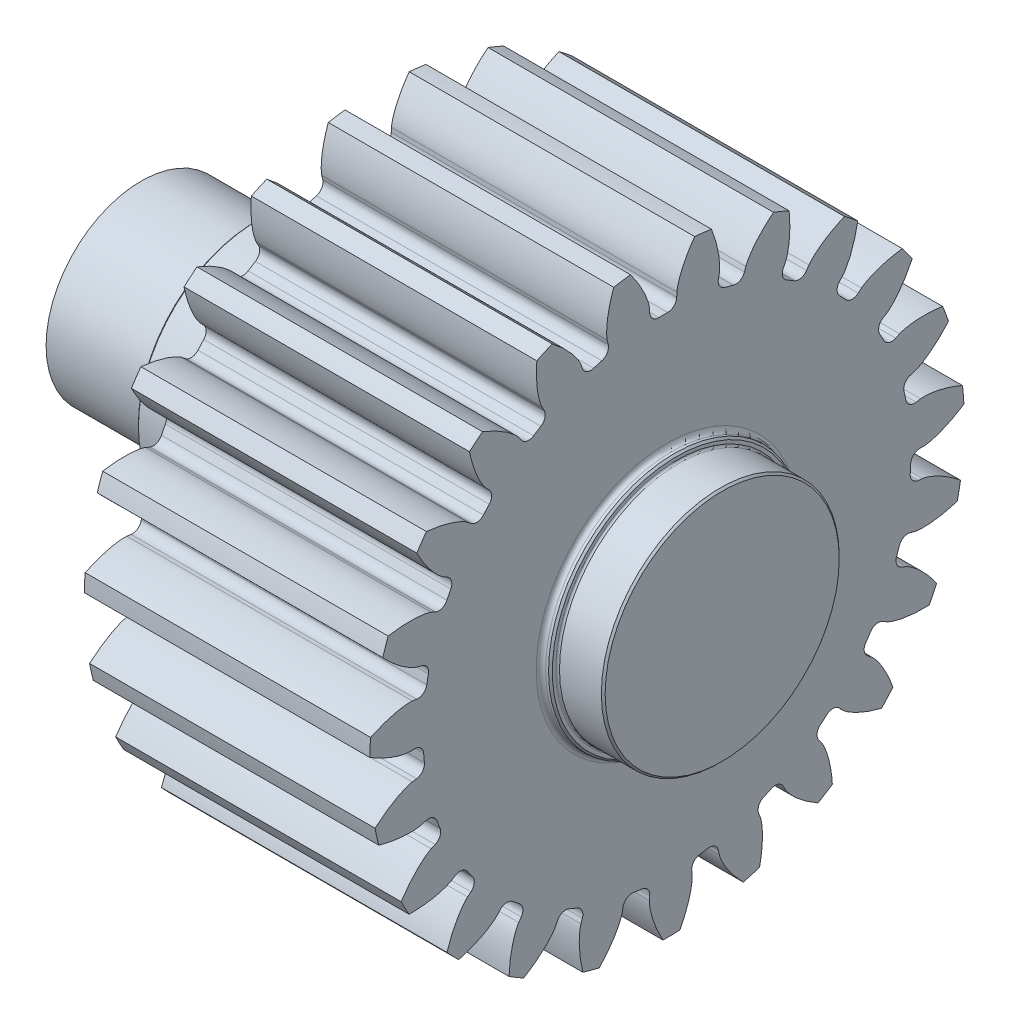
from build123d import *

# Parameters (mm, degrees)
SKETCH5_R                = 31.25
BOSS_EXTRUDE1_DEPTH      = 30
CUT_EXTRUDE2_DEPTH       = 30
FILLET2_R                = 0.95
CIRPATTERN3_COUNT        = 23
FILLET2_OF_CIRPATTERN3_R = 0.95
SKETCH12_R               = 13.25
BOSS_EXTRUDE4_DEPTH      = 1
SKETCH10_R               = 12.5
BOSS_EXTRUDE2_DEPTH      = 43.25
BOSS_EXTRUDE3_START      = -13.25
SKETCH11_R               = 10
BOSS_EXTRUDE3_DEPTH      = 12
BEARINGHOUSEFILLET_R     = 0.2
CHAMFER1_SIZE            = 0.2
FILLET4_R                = 0.5
BOSS_EXTRUDE5_START      = -43.25
SKETCH14_R               = 12.5
BOSS_EXTRUDE5_DEPTH      = 5.8
BOSS_EXTRUDE6_START      = -43.25
SKETCH14_3_R             = 13.25
SKETCH14_3_R_2           = 12.5
BOSS_EXTRUDE6_DEPTH      = 1
CHAMFER2_SIZE            = 0.2
FILLET5_R                = 0.2
FILLET6_R                = 0.5


with BuildPart() as part:
    # Sketch5 → Boss-Extrude1 (new body)
    with BuildSketch(Plane(origin=(0, 0, 0), x_dir=(0, 0, -1), z_dir=(1, 0, 0))):
        Circle(SKETCH5_R)
    extrude(amount=BOSS_EXTRUDE1_DEPTH)

    # Sketch8 → Cut-Extrude2 (cut)
    with BuildSketch(Plane(origin=(30, 0, 0), x_dir=(0, 0, -1), z_dir=(1, 0, 0))):
        with BuildLine():
            Line((27.016162848, 0), (25.625, 0))
            ThreePointArc((25.625, 0), (25.588485255, -1.367496741), (25.479045086, -2.73109621))
            Line((25.479045086, -2.73109621), (26.862284146, -2.879365462))
            add(Edge.make_bspline(
                [(26.862284146, -2.879365462), (26.874512586, -2.880882139), (26.908728932, -2.885764851), (26.973075717, -2.897476424), (27.077470202, -2.920091369), (27.20950929, -2.954038311), (27.378881389, -3.003771411), (27.576588009, -3.06984655), (27.791758211, -3.150250253), (28.023379435, -3.246062339), (28.252109809, -3.348966509), (28.477950784, -3.458370073), (28.700729243, -3.573407312), (28.967838406, -3.719835786), (29.284209391, -3.905222953), (29.647889042, -4.135986075), (30.052839087, -4.414164202), (30.405618835, -4.676716233), (30.650277923, -4.868872141), (30.795443065, -4.986981519), (30.843143694, -5.026229909)],
                knots=[0, 0, 0, 0, 0, 0.005376749, 0.015083688, 0.02853182, 0.046610139, 0.064854849, 0.092110525, 0.119476176, 0.146842496, 0.174208854, 0.201574956, 0.228941013, 0.256307345, 0.307035032, 0.361767352, 0.416499661, 0.471231936, 0.498147556, 0.498147556, 0.498147556, 0.498147556, 0.498147556], degree=4))
            ThreePointArc((30.843143694, -5.026229909), (31.205469824, -1.667678952), (31.203159657, 1.710358853))
            add(Edge.make_bspline(
                [(27.016162848, 0), (27.028483284, 0.000204739), (27.063025136, 0.001412884), (27.128253626, 0.006199711), (27.234463788, 0.017559547), (27.36936885, 0.037240492), (27.543076762, 0.068638752), (27.746699531, 0.113266094), (27.969213541, 0.17027913), (28.209727088, 0.240859447), (28.44812212, 0.318799557), (28.684336912, 0.403509993), (28.918107065, 0.494148416), (29.199301081, 0.611274537), (29.533628526, 0.761887157), (29.919831317, 0.952575153), (30.352122895, 1.186009514), (30.730875908, 1.40946706), (30.994621321, 1.574452876), (31.151547653, 1.676417917), (31.203159657, 1.710358853)],
                knots=[0, 0, 0, 0, 0, 0.005376749, 0.015083688, 0.02853182, 0.046610139, 0.064854849, 0.092110525, 0.119476176, 0.146842496, 0.174208854, 0.201574956, 0.228941013, 0.256307345, 0.307035032, 0.361767352, 0.416499661, 0.471231936, 0.498147556, 0.498147556, 0.498147556, 0.498147556, 0.498147556], degree=4))
        make_face()
    cut_extrude2 = extrude(amount=-CUT_EXTRUDE2_DEPTH, mode=Mode.SUBTRACT)

    # Fillet2
    fillet2_edges = [part.edges().sort_by_distance(p)[0] for p in [
        (15, -2.73109621, -25.479045086),
        (15, 0, -25.625),
    ]]
    fillet(fillet2_edges, radius=FILLET2_R)

    # CirPattern3: Cut-Extrude2 ×23 about axis
    cirpattern3_axis = Axis((30, 0, 0), (-1, 0, 0))
    for i in range(1, CIRPATTERN3_COUNT):
        add(cut_extrude2.rotate(cirpattern3_axis, i * 360 / CIRPATTERN3_COUNT), mode=Mode.SUBTRACT)

    # Fillet2 of CirPattern3
    fillet2_of_cirpattern3_edges = [part.edges().sort_by_distance(p)[0] for p in [
        (15, -9.50398385, -23.797372039),
        (15, -6.913542261, -24.674755488),
        (15, -15.572004486, -20.350756774),
        (15, -13.31433872, -21.894497242),
        (15, -20.485120787, -15.394818978),
        (15, -18.727671585, -17.490424295),
        (15, -23.878949392, -9.297117884),
        (15, -22.752058722, -11.789166592),
        (15, -25.501785559, -2.509892089),
        (15, -25.089029747, -5.213560334),
        (15, -25.233270955, 4.463480921),
        (15, -25.565262211, 1.748711842),
        (15, -23.093320078, 11.10581797),
        (15, -24.145436129, 8.581290062),
        (15, -19.240643296, 16.924487306),
        (15, -20.934853508, 14.777433254),
        (15, -13.960976021, 21.487944842),
        (15, -16.171628573, 19.877601824),
        (15, -7.645887021, 24.457739811),
        (15, -10.209027927, 23.503539601),
        (15, -0.763737559, 25.613616104),
        (15, -3.489270383, 25.386327367),
        (15, 6.175054824, 24.869847666),
        (15, 3.489270383, 25.386327367),
        (15, 12.65587164, 22.281596398),
        (15, 10.209027927, 23.503539601),
        (15, 18.198060353, 18.040821057),
        (15, 16.171628573, 19.877601824),
        (15, 22.39058218, 12.462040549),
        (15, 20.934853508, 14.777433254),
        (15, 24.922496957, 5.959007504),
        (15, 24.145436129, 8.581290062),
        (15, 25.606024148, -0.985977867),
        (15, 25.565262211, 1.748711842),
        (15, 24.390469667, -7.857837771),
        (15, 25.089029747, -5.213560334),
        (15, 21.36598563, -14.146917794),
        (15, 22.752058722, -11.789166592),
        (15, 16.756884182, -19.386785642),
        (15, 18.727671585, -17.490424295),
        (15, 10.905001291, -23.188824287),
        (15, 13.31433872, -21.894497242),
        (15, 4.244344342, -25.271053918),
        (15, 6.913542261, -24.674755488),
    ]]
    fillet(fillet2_of_cirpattern3_edges, radius=FILLET2_OF_CIRPATTERN3_R)

    # Sketch12 → Boss-Extrude4 (add)
    with BuildSketch(Plane(origin=(0, 0, 0), x_dir=(0, 0, -1), z_dir=(1, 0, 0))):
        Circle(SKETCH12_R)
    extrude(amount=-BOSS_EXTRUDE4_DEPTH)

    # Sketch10 → Boss-Extrude2 (add)
    with BuildSketch(Plane.ZY.offset(13.25)):
        Circle(SKETCH10_R)
    extrude(amount=-BOSS_EXTRUDE2_DEPTH)

    # Sketch11 → Boss-Extrude3 (add)
    with BuildSketch(Plane(origin=(0, 0, 0), x_dir=(0, 0, -1), z_dir=(1, 0, 0)).offset(BOSS_EXTRUDE3_START)):
        Circle(SKETCH11_R)
    extrude(amount=-BOSS_EXTRUDE3_DEPTH)

    # bearingHouseFillet
    bearinghousefillet_edges = [part.edges().sort_by_distance(p)[0] for p in [
        (-1, 0, -12.5),
    ]]
    fillet(bearinghousefillet_edges, radius=BEARINGHOUSEFILLET_R)

    # Chamfer1
    chamfer1_edges = [part.edges().sort_by_distance(p)[0] for p in [
        (-13.25, 0, -12.5),
    ]]
    chamfer(chamfer1_edges, length=CHAMFER1_SIZE)

    # Fillet4
    fillet4_edges = [part.edges().sort_by_distance(p)[0] for p in [
        (0, 0, 13.25),
    ]]
    fillet(fillet4_edges, radius=FILLET4_R)

    # Sketch14 → Boss-Extrude5 (add)
    with BuildSketch(Plane.ZY.offset(13.25).offset(BOSS_EXTRUDE5_START)):
        Circle(SKETCH14_R)
    extrude(amount=-BOSS_EXTRUDE5_DEPTH)

    # Sketch14_3 → Boss-Extrude6 (add)
    with BuildSketch(Plane.ZY.offset(13.25).offset(BOSS_EXTRUDE6_START)):
        Circle(SKETCH14_3_R)
        Circle(SKETCH14_3_R_2, mode=Mode.SUBTRACT)
    extrude(amount=-BOSS_EXTRUDE6_DEPTH)

    # Chamfer2
    chamfer2_edges = [part.edges().sort_by_distance(p)[0] for p in [
        (35.8, 0, -12.5),
        (31, 0, -13.25),
    ]]
    chamfer(chamfer2_edges, length=CHAMFER2_SIZE)

    # Fillet5
    fillet5_edges = [part.edges().sort_by_distance(p)[0] for p in [
        (31, 0, -12.5),
    ]]
    fillet(fillet5_edges, radius=FILLET5_R)

    # Fillet6
    fillet6_edges = [part.edges().sort_by_distance(p)[0] for p in [
        (30, 0, -13.25),
    ]]
    fillet(fillet6_edges, radius=FILLET6_R)


solid = part.part
